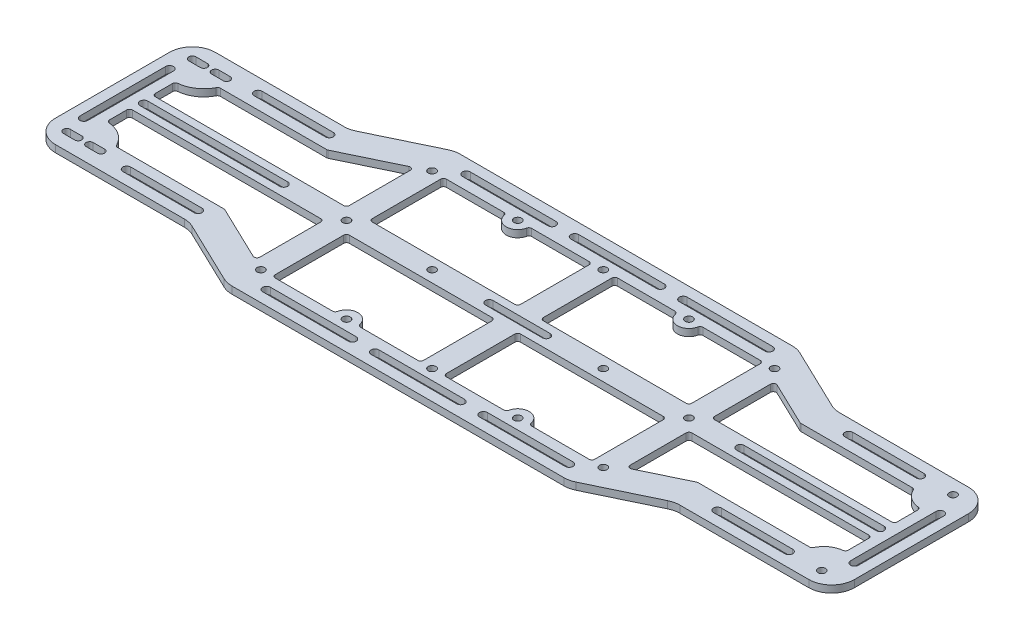
from build123d import *

# Parameters (mm, degrees)
SKETCH1_W            = 355.6
SKETCH1_H            = 101.6
BOSS_EXTRUDE1_DEPTH  = 3.175
M3_CLEARANCE_HOLE2_D = 3.4
CUT_EXTRUDE1_DEPTH   = 4.175
CUT_EXTRUDE3_DEPTH   = 4.175
FILLET1_R            = 10.16
M3_CLEARANCE_HOLE5_D = 3.4
CUT_EXTRUDE5_DEPTH   = 4.175
LPATTERN1_COUNT      = 2
LPATTERN1_PITCH      = 10.16
CUT_EXTRUDE6_DEPTH   = 4.175
CUT_EXTRUDE7_DEPTH   = 4.175
CUT_EXTRUDE8_DEPTH   = 4.175
CUT_EXTRUDE9_DEPTH   = 4.175
CUT_EXTRUDE10_DEPTH  = 4.175
CUT_EXTRUDE11_DEPTH  = 4.175
FILLET2_R            = 1.27
FILLET3_R            = 1.27
FILLET4_R            = 1.27
FILLET5_R            = 1.27
FILLET2_OF_MIRROR3_R = 1.27
FILLET3_OF_MIRROR3_R = 1.27
FILLET4_OF_MIRROR3_R = 1.27
FILLET5_OF_MIRROR3_R = 1.27


with BuildPart() as part:
    # Sketch1 → Boss-Extrude1 (new body)
    with BuildSketch(Plane(origin=(0, 0, 0), x_dir=(1, 0, 0), z_dir=(0, 1, 0))):
        with Locations((177.8, 50.8)):
            Rectangle(SKETCH1_W, SKETCH1_H)
    extrude(amount=BOSS_EXTRUDE1_DEPTH)

    # M3 Clearance Hole2 (through all)
    with Locations(Plane(origin=(0, 0, 0), x_dir=(-1, 0, 0), z_dir=(0, -1, 0))):
        with Locations((-344.86342, 21.59), (-344.86342, 80.01)):
            Hole(M3_CLEARANCE_HOLE2_D / 2)

    # Sketch7 → Cut-Extrude1 (cut, through all)
    with BuildSketch(Plane.XZ):
        with BuildLine():
            Line((7.62, -21.283803), (12.7, -21.283803))
            ThreePointArc((12.7, -21.283803), (14.276197, -22.86), (12.7, -24.436197))
            Line((12.7, -24.436197), (7.62, -24.436197))
            ThreePointArc((7.62, -24.436197), (6.043803, -22.86), (7.62, -21.283803))
        make_face()
        with BuildLine():
            Line((7.62, -80.316197), (12.7, -80.316197))
            ThreePointArc((12.7, -80.316197), (14.276197, -78.74), (12.7, -77.163803))
            Line((12.7, -77.163803), (7.62, -77.163803))
            ThreePointArc((7.62, -77.163803), (6.043803, -78.74), (7.62, -80.316197))
        make_face()
    cut_extrude1 = extrude(amount=-CUT_EXTRUDE1_DEPTH, mode=Mode.SUBTRACT)

    # Sketch16 → Cut-Extrude3 (cut, through all)
    with BuildSketch(Plane(origin=(0, 3.175, 0), x_dir=(1, 0, 0), z_dir=(0, 1, 0))):
        Polygon((355.6, 15.24), (285.75, 15.24), (254, 0), (355.6, 0), align=None)
        Polygon((69.85, 15.24), (101.6, 0), (0, 0), (0, 15.24), align=None)
        Polygon((0, 86.36), (69.85, 86.36), (101.6, 101.6), (0, 101.6), align=None)
        Polygon((285.75, 86.36), (254, 101.6), (355.6, 101.6), (355.6, 86.36), align=None)
    extrude(amount=-CUT_EXTRUDE3_DEPTH, mode=Mode.SUBTRACT)

    # Fillet1
    fillet1_edges = [part.edges().sort_by_distance(p)[0] for p in [
        (355.6, 1.5875, -15.24),
        (254, 1.5875, 0),
        (285.75, 1.5875, -15.24),
        (0, 1.5875, -15.24),
        (69.85, 1.5875, -15.24),
        (101.6, 1.5875, 0),
        (0, 1.5875, -86.36),
        (101.6, 1.5875, -101.6),
        (69.85, 1.5875, -86.36),
        (355.6, 1.5875, -86.36),
        (285.75, 1.5875, -86.36),
        (254, 1.5875, -101.6),
    ]]
    fillet(fillet1_edges, radius=FILLET1_R)

    # M3 Clearance Hole5 (through all)
    with Locations(Plane(origin=(0, 3.175, 0), x_dir=(1, 0, 0), z_dir=(0, 1, 0))):
        with Locations((104.14, 88.9), (142.24, 88.9), (180.34, 88.9), (218.44, 88.9), (256.54, 88.9), (256.54, 12.7), (218.44, 12.7), (180.34, 12.7), (142.24, 12.7), (104.14, 12.7), (104.14, 50.8), (256.54, 50.8), (142.24, 50.8), (180.34, 50.8), (218.44, 50.8)):
            Hole(M3_CLEARANCE_HOLE5_D / 2)

    # Sketch20 → Cut-Extrude5 (cut, through all)
    with BuildSketch(Plane(origin=(0, 3.175, 0), x_dir=(1, 0, 0), z_dir=(0, 1, 0))):
        with BuildLine():
            Line((167.64, 52.5), (193.04, 52.5))
            ThreePointArc((193.04, 52.5), (194.74, 50.8), (193.04, 49.1))
            Line((193.04, 49.1), (167.64, 49.1))
            ThreePointArc((167.64, 49.1), (165.94, 50.8), (167.64, 52.5))
        make_face()
    extrude(amount=-CUT_EXTRUDE5_DEPTH, mode=Mode.SUBTRACT)

    # LPattern1: Cut-Extrude1 ×2
    with Locations(*[(i * LPATTERN1_PITCH, 0, 0) for i in range(1, LPATTERN1_COUNT)]):
        add(cut_extrude1, mode=Mode.SUBTRACT)

    # Sketch22 → Cut-Extrude6 (cut, through all)
    with BuildSketch(Plane(origin=(0, 3.175, 0), x_dir=(1, 0, 0), z_dir=(0, 1, 0))):
        with BuildLine():
            Line((13.97, 52.55), (76.2, 52.55))
            ThreePointArc((76.2, 52.55), (77.95, 50.8), (76.2, 49.05))
            Line((76.2, 49.05), (13.97, 49.05))
            ThreePointArc((13.97, 49.05), (12.22, 50.8), (13.97, 52.55))
        make_face()
    extrude(amount=-CUT_EXTRUDE6_DEPTH, mode=Mode.SUBTRACT)

    # Sketch23 → Cut-Extrude7 (cut, through all)
    with BuildSketch(Plane(origin=(0, 3.175, 0), x_dir=(1, 0, 0), z_dir=(0, 1, 0))):
        with BuildLine():
            Line((279.4, 52.55), (341.63, 52.55))
            ThreePointArc((341.63, 52.55), (343.38, 50.8), (341.63, 49.05))
            Line((341.63, 49.05), (279.4, 49.05))
            ThreePointArc((279.4, 49.05), (277.65, 50.8), (279.4, 52.55))
        make_face()
    extrude(amount=-CUT_EXTRUDE7_DEPTH, mode=Mode.SUBTRACT)

    # Sketch24 → Cut-Extrude8 (cut, through all)
    with BuildSketch(Plane(origin=(0, 3.175, 0), x_dir=(1, 0, 0), z_dir=(0, 1, 0))):
        with BuildLine():
            Line((8.1, 69.85), (8.1, 31.75))
            ThreePointArc((8.1, 31.75), (6.35, 30), (4.6, 31.75))
            Line((4.6, 31.75), (4.6, 69.85))
            ThreePointArc((4.6, 69.85), (6.35, 71.6), (8.1, 69.85))
        make_face()
        with BuildLine():
            Line((351, 69.85), (351, 31.75))
            ThreePointArc((351, 31.75), (349.25, 30), (347.5, 31.75))
            Line((347.5, 31.75), (347.5, 69.85))
            ThreePointArc((347.5, 69.85), (349.25, 71.6), (351, 69.85))
        make_face()
    extrude(amount=-CUT_EXTRUDE8_DEPTH, mode=Mode.SUBTRACT)

    # Sketch25 → Cut-Extrude9 (cut, through all)
    with BuildSketch(Plane(origin=(0, 3.175, 0), x_dir=(1, 0, 0), z_dir=(0, 1, 0))):
        with BuildLine():
            Line((113.03, 97), (151.13, 97))
            ThreePointArc((151.13, 97), (152.88, 95.25), (151.13, 93.5))
            Line((151.13, 93.5), (113.03, 93.5))
            ThreePointArc((113.03, 93.5), (111.28, 95.25), (113.03, 97))
        make_face()
        with BuildLine():
            Line((161.29, 97), (199.39, 97))
            ThreePointArc((199.39, 97), (201.14, 95.25), (199.39, 93.5))
            Line((199.39, 93.5), (161.29, 93.5))
            ThreePointArc((161.29, 93.5), (159.54, 95.25), (161.29, 97))
        make_face()
        with BuildLine():
            Line((209.55, 97), (247.65, 97))
            ThreePointArc((247.65, 97), (249.4, 95.25), (247.65, 93.5))
            Line((247.65, 93.5), (209.55, 93.5))
            ThreePointArc((209.55, 93.5), (207.8, 95.25), (209.55, 97))
        make_face()
    cut_extrude9 = extrude(amount=-CUT_EXTRUDE9_DEPTH, mode=Mode.SUBTRACT)

    # Mirror1: Cut-Extrude9 across plane
    add(cut_extrude9.mirror(Plane(origin=(0, 0, -50.8), x_dir=(1, 0, 0), z_dir=(0, 0, -1))), mode=Mode.SUBTRACT)

    # Sketch26 → Cut-Extrude10 (cut, through all)
    with BuildSketch(Plane(origin=(0, 3.175, 0), x_dir=(1, 0, 0), z_dir=(0, 1, 0))):
        with BuildLine():
            Line((35.56, 81.76), (67.31, 81.76))
            ThreePointArc((67.31, 81.76), (69.06, 80.01), (67.31, 78.26))
            Line((67.31, 78.26), (35.56, 78.26))
            ThreePointArc((35.56, 78.26), (33.81, 80.01), (35.56, 81.76))
        make_face()
        with BuildLine():
            Line((298.45, 81.76), (330.2, 81.76))
            ThreePointArc((330.2, 81.76), (331.95, 80.01), (330.2, 78.26))
            Line((330.2, 78.26), (298.45, 78.26))
            ThreePointArc((298.45, 78.26), (296.7, 80.01), (298.45, 81.76))
        make_face()
    cut_extrude10 = extrude(amount=-CUT_EXTRUDE10_DEPTH, mode=Mode.SUBTRACT)

    # Mirror2: Cut-Extrude10 across plane
    add(cut_extrude10.mirror(Plane(origin=(0, 0, -50.8), x_dir=(1, 0, 0), z_dir=(0, 0, -1))), mode=Mode.SUBTRACT)

    # Sketch28 → Cut-Extrude11 (cut, through all)
    with BuildSketch(Plane(origin=(0, 3.175, 0), x_dir=(1, 0, 0), z_dir=(0, 1, 0))):
        with BuildLine():
            Line((12.7, 55.88), (12.7, 66.04))
            ThreePointArc((12.7, 66.04), (19.65607648, 68.114417663), (24.339742265, 73.66))
            Line((24.339742265, 73.66), (72.740148787, 73.66))
            Line((72.740148787, 73.66), (99.06, 86.293528582))
            Line((99.06, 86.293528582), (99.06, 55.88))
            Line((99.06, 55.88), (12.7, 55.88))
        make_face()
        with BuildLine():
            Line((109.22, 88.9), (109.22, 55.88))
            Line((109.22, 55.88), (175.26, 55.88))
            Line((175.26, 55.88), (175.26, 88.9))
            Line((175.26, 88.9), (147.32, 88.9))
            ThreePointArc((147.32, 88.9), (142.24, 83.82), (137.16, 88.9))
            Line((137.16, 88.9), (109.22, 88.9))
        make_face()
        with BuildLine():
            Line((185.42, 88.9), (185.42, 55.88))
            Line((185.42, 55.88), (251.46, 55.88))
            Line((251.46, 55.88), (251.46, 88.9))
            Line((251.46, 88.9), (223.52, 88.9))
            ThreePointArc((223.52, 88.9), (218.44, 83.82), (213.36, 88.9))
            Line((213.36, 88.9), (185.42, 88.9))
        make_face()
        with BuildLine():
            Line((342.9, 55.88), (342.9, 67.462690252))
            ThreePointArc((342.9, 67.462690252), (337.421867846, 69.160907383), (333.864897372, 73.66))
            Line((333.864897372, 73.66), (287.02, 73.66))
            Line((287.02, 73.66), (283.21, 73.66))
            Line((283.21, 73.66), (261.62, 84.0232))
            Line((261.62, 84.0232), (261.62, 55.88))
            Line((261.62, 55.88), (342.9, 55.88))
        make_face()
    cut_extrude11 = extrude(amount=-CUT_EXTRUDE11_DEPTH, mode=Mode.SUBTRACT)

    # Fillet2
    fillet2_edges = [part.edges().sort_by_distance(p)[0] for p in [
        (99.06, 1.5875, -86.293528582),
        (261.62, 1.5875, -84.0232),
    ]]
    fillet(fillet2_edges, radius=FILLET2_R)

    # Fillet3
    fillet3_edges = [part.edges().sort_by_distance(p)[0] for p in [
        (99.06, 1.5875, -55.88),
        (12.7, 1.5875, -55.88),
        (12.7, 1.5875, -66.04),
        (24.339742265, 1.5875, -73.66),
        (72.740148787, 1.5875, -73.66),
    ]]
    fillet(fillet3_edges, radius=FILLET3_R)

    # Fillet4
    fillet4_edges = [part.edges().sort_by_distance(p)[0] for p in [
        (109.22, 1.5875, -88.9),
        (137.16, 1.5875, -88.9),
        (147.32, 1.5875, -88.9),
        (175.26, 1.5875, -88.9),
        (175.26, 1.5875, -55.88),
        (109.22, 1.5875, -55.88),
        (185.42, 1.5875, -88.9),
        (213.36, 1.5875, -88.9),
        (223.52, 1.5875, -88.9),
        (251.46, 1.5875, -88.9),
        (251.46, 1.5875, -55.88),
        (185.42, 1.5875, -55.88),
    ]]
    fillet(fillet4_edges, radius=FILLET4_R)

    # Fillet5
    fillet5_edges = [part.edges().sort_by_distance(p)[0] for p in [
        (342.9, 1.5875, -55.88),
        (261.62, 1.5875, -55.88),
        (283.21, 1.5875, -73.66),
        (333.864897372, 1.5875, -73.66),
        (342.9, 1.5875, -67.462690252),
    ]]
    fillet(fillet5_edges, radius=FILLET5_R)

    # Mirror3: Cut-Extrude11 across plane
    add(cut_extrude11.mirror(Plane(origin=(0, 0, -50.8), x_dir=(1, 0, 0), z_dir=(0, 0, -1))), mode=Mode.SUBTRACT)

    # Fillet2 of Mirror3
    fillet2_of_mirror3_edges = [part.edges().sort_by_distance(p)[0] for p in [
        (99.06, 1.5875, -15.306471418),
        (261.62, 1.5875, -17.5768),
    ]]
    fillet(fillet2_of_mirror3_edges, radius=FILLET2_OF_MIRROR3_R)

    # Fillet3 of Mirror3
    fillet3_of_mirror3_edges = [part.edges().sort_by_distance(p)[0] for p in [
        (99.06, 1.5875, -45.72),
        (12.7, 1.5875, -45.72),
        (12.7, 1.5875, -35.56),
        (24.339742265, 1.5875, -27.94),
        (72.740148787, 1.5875, -27.94),
    ]]
    fillet(fillet3_of_mirror3_edges, radius=FILLET3_OF_MIRROR3_R)

    # Fillet4 of Mirror3
    fillet4_of_mirror3_edges = [part.edges().sort_by_distance(p)[0] for p in [
        (109.22, 1.5875, -12.7),
        (137.16, 1.5875, -12.7),
        (147.32, 1.5875, -12.7),
        (175.26, 1.5875, -12.7),
        (175.26, 1.5875, -45.72),
        (109.22, 1.5875, -45.72),
        (185.42, 1.5875, -12.7),
        (213.36, 1.5875, -12.7),
        (223.52, 1.5875, -12.7),
        (251.46, 1.5875, -12.7),
        (251.46, 1.5875, -45.72),
        (185.42, 1.5875, -45.72),
    ]]
    fillet(fillet4_of_mirror3_edges, radius=FILLET4_OF_MIRROR3_R)

    # Fillet5 of Mirror3
    fillet5_of_mirror3_edges = [part.edges().sort_by_distance(p)[0] for p in [
        (342.9, 1.5875, -45.72),
        (261.62, 1.5875, -45.72),
        (283.21, 1.5875, -27.94),
        (333.864897372, 1.5875, -27.94),
        (342.9, 1.5875, -34.137309748),
    ]]
    fillet(fillet5_of_mirror3_edges, radius=FILLET5_OF_MIRROR3_R)


solid = part.part
